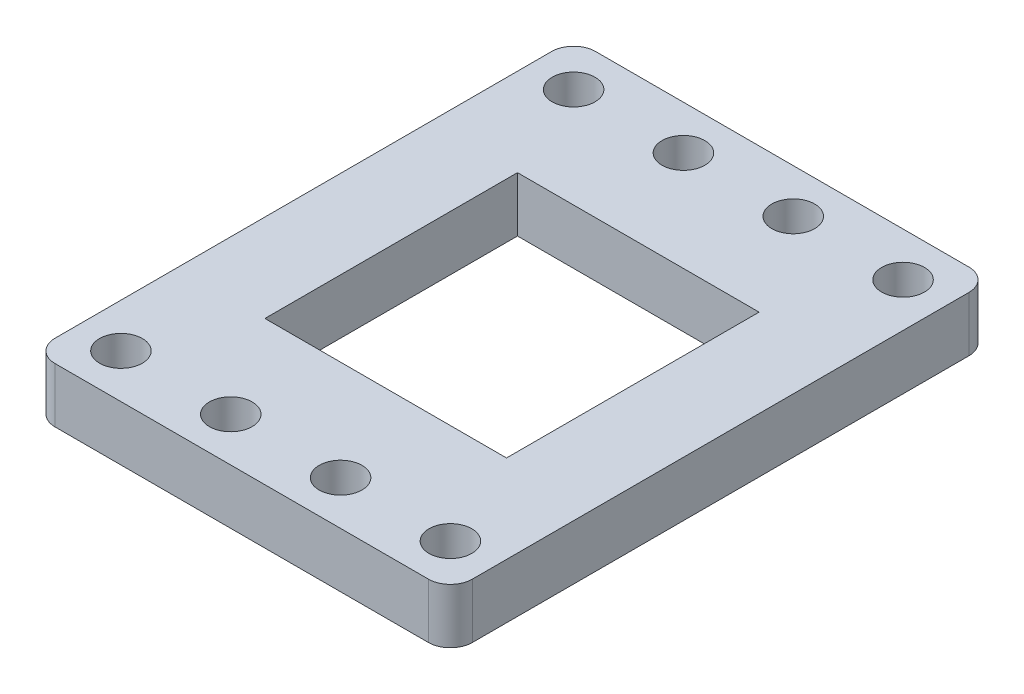
from build123d import *

# Parameters (mm, degrees)
BOSS_EXTRUDE1_DEPTH = 5
SKETCH2_R           = 1.95
SKETCH2_W           = 22
SKETCH2_H           = 23
CUT_EXTRUDE1_DEPTH  = 6


with BuildPart() as part:
    # Sketch1 → Boss-Extrude1 (new body)
    with BuildSketch(Plane(origin=(0, 0, 0), x_dir=(1, 0, 0), z_dir=(0, 1, 0))):
        with BuildLine():
            Line((-36, 0), (-2, 0))
            ThreePointArc((-2, 0), (-0.585786438, -0.585786438), (0, -2))
            Line((0, -2), (0, -47.22))
            ThreePointArc((0, -47.22), (-0.585786438, -48.634213562), (-2, -49.22))
            Line((-2, -49.22), (-36, -49.22))
            ThreePointArc((-36, -49.22), (-37.414213562, -48.634213562), (-38, -47.22))
            Line((-38, -47.22), (-38, -2))
            ThreePointArc((-38, -2), (-37.414213562, -0.585786438), (-36, 0))
        make_face()
    extrude(amount=BOSS_EXTRUDE1_DEPTH)

    # Sketch2 → Cut-Extrude1 (cut, through all)
    with BuildSketch(Plane(origin=(0, 5, 0), x_dir=(1, 0, 0), z_dir=(0, 1, 0))):
        with Locations((-4, -4)):
            Circle(SKETCH2_R)
        with Locations((-14, -4)):
            Circle(SKETCH2_R)
        with Locations((-24, -4)):
            Circle(SKETCH2_R)
        with Locations((-54, -4)):
            Circle(SKETCH2_R)
        with Locations((-34, -4)):
            Circle(SKETCH2_R)
        with Locations((-44, -4)):
            Circle(SKETCH2_R)
        with Locations((-44, -45.22)):
            Circle(SKETCH2_R)
        with Locations((-34, -45.22)):
            Circle(SKETCH2_R)
        with Locations((-54, -45.22)):
            Circle(SKETCH2_R)
        with Locations((-24, -45.22)):
            Circle(SKETCH2_R)
        with Locations((-14, -45.22)):
            Circle(SKETCH2_R)
        with Locations((-4, -45.22)):
            Circle(SKETCH2_R)
        with Locations((-19, -24.61)):
            Rectangle(SKETCH2_W, SKETCH2_H)
    extrude(amount=-CUT_EXTRUDE1_DEPTH, mode=Mode.SUBTRACT)


solid = part.part
